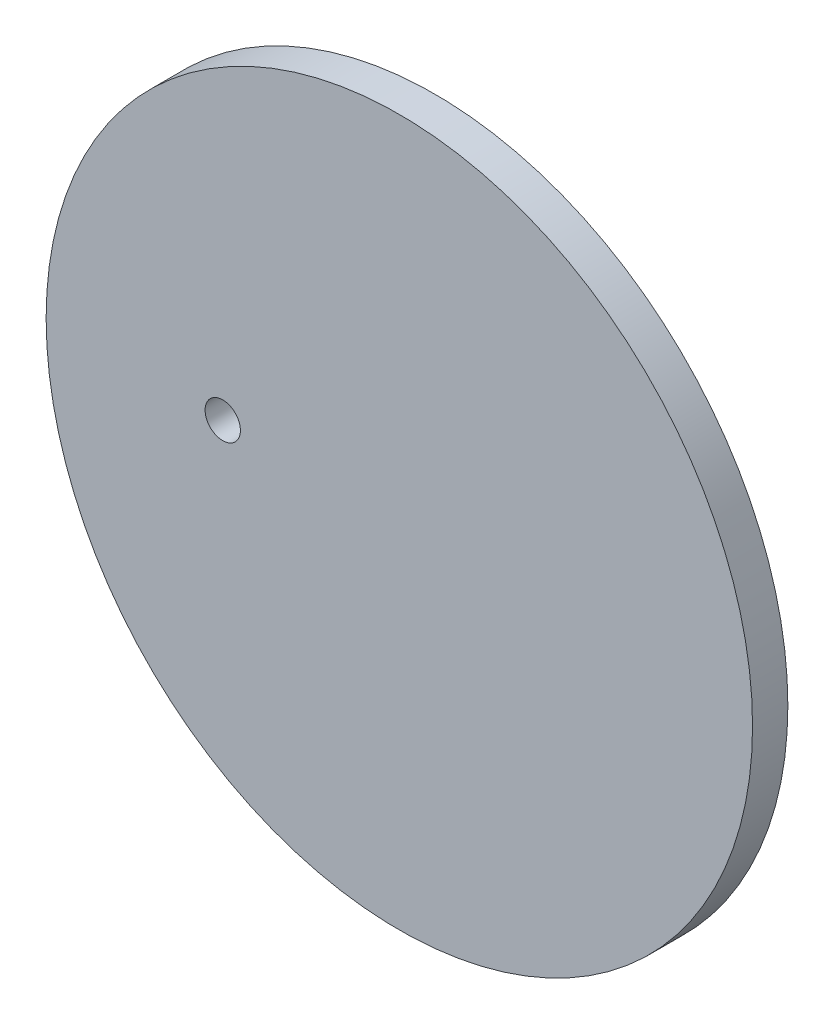
from build123d import *

# Parameters (mm, degrees)
SKETCH_1_R      = 40
SKETCH_1_R_2    = 2
EXTRUDE_1_DEPTH = 2


with BuildPart() as part:
    # 草图1 → 凸台-拉伸1 (new body, symmetric)
    with BuildSketch(Plane.XY):
        Circle(SKETCH_1_R)
        with Locations((-20, 0)):
            Circle(SKETCH_1_R_2, mode=Mode.SUBTRACT)
    extrude(amount=EXTRUDE_1_DEPTH, both=True)


solid = part.part
